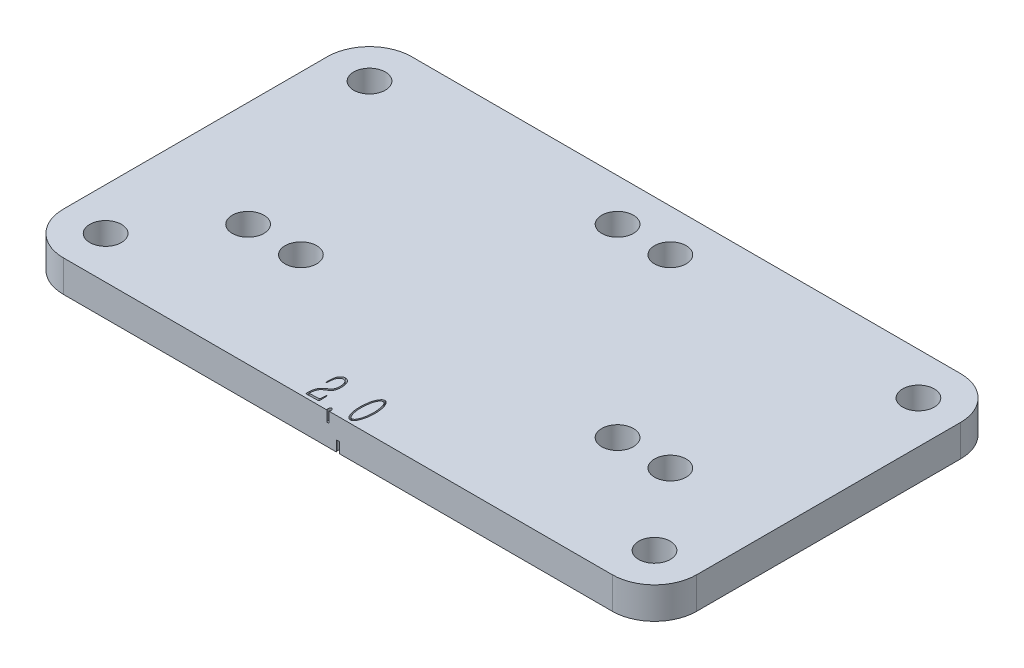
from build123d import *

# Parameters (mm, degrees)
SKETCH_4_W          = 60
SKETCH_4_H          = 33
EXTRUDE_2_DEPTH     = 3
SKETCH_8_R          = 1.5
CUT_EXTRUDE_6_DEPTH = 4
FILLET_2_R          = 4
SKETCH_7_R          = 1.5
CUT_EXTRUDE_7_DEPTH = 4
CUT_EXTRUDE_8_DEPTH = 1
CUT_EXTRUDE_9_DEPTH = 1


with BuildPart() as part:
    # 草图4 → 凸台-拉伸2 (new body)
    with BuildSketch(Plane(origin=(0, 0, 0), x_dir=(1, 0, 0), z_dir=(0, 1, 0))):
        with Locations((-12.012320329, 24.45687885)):
            Rectangle(SKETCH_4_W, SKETCH_4_H)
    extrude(amount=-EXTRUDE_2_DEPTH)

    # 草图8 → 切除-拉伸6 (cut)
    with BuildSketch(Plane(origin=(0, 0, 0), x_dir=(1, 0, 0), z_dir=(0, 1, 0))):
        with Locations((-38.012320329, 36.95687885)):
            Circle(SKETCH_8_R)
        with Locations((13.987679671, 36.95687885)):
            Circle(SKETCH_8_R)
        with Locations((13.987679671, 11.95687885)):
            Circle(SKETCH_8_R)
        with Locations((-38.012320329, 11.95687885)):
            Circle(SKETCH_8_R)
    extrude(amount=-CUT_EXTRUDE_6_DEPTH, mode=Mode.SUBTRACT)

    # 圆角2
    fillet_2_edges = [part.edges().sort_by_distance(p)[0] for p in [
        (-42.012320329, -1.5, -7.95687885),
        (-42.012320329, -1.5, -40.95687885),
        (17.987679671, -1.5, -40.95687885),
        (17.987679671, -1.5, -7.95687885),
    ]]
    fillet(fillet_2_edges, radius=FILLET_2_R)

    # 草图7 → 切除-拉伸7 (cut, through all)
    with BuildSketch(Plane(origin=(0, 0, 0), x_dir=(1, 0, 0), z_dir=(0, 1, 0))):
        with Locations((-14.512320329, 36.95687885)):
            Circle(SKETCH_7_R)
        with Locations((2.987679671, 19.45687885)):
            Circle(SKETCH_7_R)
        with Locations((-32.012320329, 19.45687885)):
            Circle(SKETCH_7_R)
        with Locations((-9.512320329, 36.95687885)):
            Circle(SKETCH_7_R)
        with Locations((7.987679671, 19.45687885)):
            Circle(SKETCH_7_R)
        with Locations((-27.012320329, 19.45687885)):
            Circle(SKETCH_7_R)
    extrude(amount=-CUT_EXTRUDE_7_DEPTH, mode=Mode.SUBTRACT)

    # 草图10 → 切除-拉伸8 (cut)
    with BuildSketch(Plane(origin=(0, 0, 0), x_dir=(1, 0, 0), z_dir=(0, 1, 0))):
        with BuildLine():
            Line((-15.287091264, 10.192016289), (-15.363162008, 10.192016289))
            add(Edge.make_bspline(
                [(-15.363162008, 10.192016289), (-15.364729412, 10.216125544), (-15.367717543, 10.26208793), (-15.370800887, 10.327727204), (-15.372102998, 10.386663248), (-15.373407415, 10.45851319), (-15.371395676, 10.549125051), (-15.365993988, 10.6221094), (-15.363162008, 10.660373416)],
                knots=[0, 0, 0, 0, 7.248e-05, 0.000138177, 0.000197114, 0.000249325, 0.000353759, 0.000468853, 0.000468853, 0.000468853, 0.000468853], degree=3))
            add(Edge.make_bspline(
                [(-15.363162008, 10.660373416), (-15.3612021, 10.688739694), (-15.357411864, 10.743596824), (-15.34740886, 10.82265933), (-15.335832353, 10.895923705), (-15.320781798, 10.96483426), (-15.300446018, 11.03227012), (-15.271495836, 11.100098975), (-15.235389503, 11.170644039), (-15.192730832, 11.241435985), (-15.145924194, 11.308233867), (-15.093385686, 11.362591116), (-15.038399866, 11.404022313), (-14.979896259, 11.428680189), (-14.92372432, 11.44401387), (-14.872500115, 11.456075445), (-14.826468535, 11.464504855), (-14.797385804, 11.465404455), (-14.783681931, 11.465828349)],
                knots=[0, 0, 0, 0, 8.5285e-05, 0.000164931, 0.000238986, 0.000307745, 0.000376394, 0.000449941, 0.000528656, 0.000613967, 0.000697805, 0.000772696, 0.000839975, 0.00090275, 0.000961757, 0.001014582, 0.001060683, 0.001101762, 0.001101762, 0.001101762, 0.001101762], degree=3))
            add(Edge.make_bspline(
                [(-14.783681931, 11.465828349), (-14.766217736, 11.464540667), (-14.731709026, 11.461996248), (-14.68094767, 11.450207253), (-14.631922619, 11.433209283), (-14.569217924, 11.402929262), (-14.495894876, 11.355454365), (-14.433516497, 11.293111961), (-14.39035243, 11.236045645), (-14.359947578, 11.187477797), (-14.333004081, 11.133245042), (-14.299167978, 11.054443003), (-14.263770709, 10.94987198), (-14.238244007, 10.817798054), (-14.221876916, 10.680645161), (-14.214388449, 10.5404336), (-14.212996049, 10.401603983), (-14.221147783, 10.311061559), (-14.225084019, 10.267341241)],
                knots=[0, 0, 0, 0, 5.2466e-05, 0.000103671, 0.000155796, 0.000207836, 0.000312295, 0.000416185, 0.00047048, 0.000526766, 0.000587802, 0.000651945, 0.000784015, 0.000917992, 0.001054714, 0.001198141, 0.001339096, 0.001470713, 0.001470713, 0.001470713, 0.001470713], degree=3))
            add(Edge.make_bspline(
                [(-14.225084019, 10.267341241), (-14.233063394, 10.222368993), (-14.249141197, 10.131753505), (-14.283770883, 10.022653706), (-14.316066991, 9.939709743), (-14.343068232, 9.884128838), (-14.371918792, 9.83492425), (-14.413636529, 9.77673495), (-14.477344962, 9.710683589), (-14.53638122, 9.666388782), (-14.567402366, 9.643113668)],
                knots=[0, 0, 0, 0, 0.000136901, 0.000275845, 0.000342458, 0.000403831, 0.000461005, 0.00051337, 0.000618346, 0.000734587, 0.000734587, 0.000734587, 0.000734587], degree=3))
            Line((-14.567402366, 9.643113668), (-14.814259387, 9.487243223))
            add(Edge.make_bspline(
                [(-14.814259387, 9.487243223), (-14.845716391, 9.465887458), (-14.905364874, 9.425392853), (-14.985012067, 9.359246819), (-15.051862567, 9.289550735), (-15.102391662, 9.212487486), (-15.141636573, 9.133161687), (-15.176484806, 9.05351083), (-15.20279345, 8.965717253), (-15.22150518, 8.887025399), (-15.234265961, 8.82093608), (-15.240658092, 8.77484398), (-15.245850832, 8.734107217), (-15.246509446, 8.708650398), (-15.246818517, 8.696704122)],
                knots=[0, 0, 0, 0, 0.000114009, 0.000216182, 0.000310104, 0.000402565, 0.000491286, 0.000575504, 0.000663016, 0.000765762, 0.000818127, 0.000864851, 0.000905372, 0.000941201, 0.000941201, 0.000941201, 0.000941201], degree=3))
            Line((-15.246818517, 8.696704122), (-15.2572596, 8.485645098))
            Line((-15.2572596, 8.485645098), (-14.356343342, 8.515476762))
            add(Edge.make_bspline(
                [(-14.356343342, 8.515476762), (-14.344783063, 8.516123127), (-14.324478623, 8.5172584), (-14.304964808, 8.538531786), (-14.300621259, 8.564506607), (-14.2929139, 8.596454889), (-14.287184007, 8.6422499), (-14.282763796, 8.677076254), (-14.280272598, 8.696704122)],
                knots=[0, 0, 0, 0, 3.3494e-05, 5.8829e-05, 7.891e-05, 0.000111674, 0.00015766, 0.000217048, 0.000217048, 0.000217048, 0.000217048], degree=3))
            Line((-14.280272598, 8.696704122), (-14.260136225, 9.135229585))
            Line((-14.260136225, 9.135229585), (-14.190031814, 9.135229585))
            Line((-14.190031814, 9.135229585), (-14.164674899, 8.470729266))
            add(Edge.make_bspline(
                [(-14.164674899, 8.470729266), (-14.163827204, 8.457810655), (-14.162344584, 8.435215992), (-14.161622864, 8.405326519), (-14.161602437, 8.384513996), (-14.161917205, 8.367709996), (-14.167329396, 8.353017942), (-14.172358408, 8.335970323), (-14.191976116, 8.326339221), (-14.220175179, 8.323257692), (-14.263031484, 8.318893416), (-14.296667332, 8.319172549), (-14.316070595, 8.31933357)],
                knots=[0, 0, 0, 0, 3.8846e-05, 6.7941e-05, 8.9569e-05, 0.000101525, 0.000117813, 0.000136827, 0.000151537, 0.00017962, 0.000222294, 0.00028047, 0.00028047, 0.00028047, 0.00028047], degree=3))
            Line((-14.316070595, 8.31933357), (-15.31766872, 8.293976655))
            add(Edge.make_bspline(
                [(-15.31766872, 8.293976655), (-15.329844159, 8.293941037), (-15.353842849, 8.293870829), (-15.378435843, 8.317734804), (-15.388759475, 8.346948947), (-15.393926411, 8.381310643), (-15.397387349, 8.426897236), (-15.399049769, 8.505303374), (-15.395495567, 8.616863261), (-15.387489826, 8.708917686), (-15.383298381, 8.757113242)],
                knots=[0, 0, 0, 0, 3.5337e-05, 6.9651e-05, 9.3748e-05, 0.000127835, 0.000173481, 0.000230926, 0.000362984, 0.0005081, 0.0005081, 0.0005081, 0.0005081], degree=3))
            add(Edge.make_bspline(
                [(-15.383298381, 8.757113242), (-15.379578821, 8.785244923), (-15.372413658, 8.839436306), (-15.357845202, 8.917442036), (-15.342312867, 8.989848815), (-15.325456184, 9.056612837), (-15.306847234, 9.117382375), (-15.286535618, 9.172087858), (-15.265479497, 9.221610342), (-15.233852113, 9.27763323), (-15.193656168, 9.338700066), (-15.147935489, 9.404544814), (-15.103915379, 9.460398843), (-15.046378949, 9.521847278), (-14.96848564, 9.588918856), (-14.903050304, 9.638030329), (-14.869447965, 9.663250041)],
                knots=[0, 0, 0, 0, 8.5115e-05, 0.000163961, 0.000237979, 0.000307257, 0.000370478, 0.000428525, 0.00048229, 0.000531692, 0.000621268, 0.000701551, 0.000772134, 0.000834397, 0.000953808, 0.001079855, 0.001079855, 0.001079855, 0.001079855], degree=3))
            Line((-14.869447965, 9.663250041), (-14.662863691, 9.794509364))
            add(Edge.make_bspline(
                [(-14.662863691, 9.794509364), (-14.64632441, 9.805505683), (-14.614585732, 9.826607485), (-14.570747877, 9.860203266), (-14.533374461, 9.895061277), (-14.50116727, 9.932677624), (-14.472011716, 9.976205072), (-14.448067406, 10.030461354), (-14.422753928, 10.094370031), (-14.393239818, 10.19379999), (-14.362808637, 10.325038793), (-14.351143021, 10.487189504), (-14.357374899, 10.6514431), (-14.376426923, 10.760463114), (-14.386175006, 10.816243862)],
                knots=[0, 0, 0, 0, 5.9575e-05, 0.000114323, 0.000165501, 0.00021258, 0.000262637, 0.00032202, 0.000390023, 0.000468816, 0.000632947, 0.00079305, 0.000955026, 0.001124734, 0.001124734, 0.001124734, 0.001124734], degree=3))
            add(Edge.make_bspline(
                [(-14.386175006, 10.816243862), (-14.393520352, 10.844680862), (-14.407846215, 10.900142457), (-14.434960955, 10.980037045), (-14.470059325, 11.052803115), (-14.507626842, 11.1207778), (-14.554691839, 11.180279134), (-14.617383125, 11.223012928), (-14.691444372, 11.251579484), (-14.745618308, 11.256609889), (-14.77398664, 11.259244075)],
                knots=[0, 0, 0, 0, 8.8108e-05, 0.000171839, 0.000252578, 0.000330097, 0.000404769, 0.000477598, 0.000555024, 0.000640139, 0.000640139, 0.000640139, 0.000640139], degree=3))
            add(Edge.make_bspline(
                [(-14.77398664, 11.259244075), (-14.788919036, 11.259396951), (-14.818702747, 11.259701874), (-14.863064269, 11.252974573), (-14.906211961, 11.238869255), (-14.962890377, 11.213304149), (-15.028383427, 11.165683274), (-15.097319789, 11.0938324), (-15.154181325, 11.006100918), (-15.197960353, 10.904436132), (-15.230878923, 10.788612226), (-15.257602358, 10.658805092), (-15.275149735, 10.513368621), (-15.280052172, 10.41157402), (-15.282616514, 10.358327817)],
                knots=[0, 0, 0, 0, 4.4754e-05, 8.9264e-05, 0.000133844, 0.000180568, 0.00027533, 0.000374495, 0.000477921, 0.000587115, 0.000705339, 0.000838586, 0.000984372, 0.001144266, 0.001144266, 0.001144266, 0.001144266], degree=3))
            Line((-15.282616514, 10.358327817), (-15.287091264, 10.192016289))
        make_face()
        with BuildLine():
            add(Edge.make_bspline(
                [(-12.949780375, 8.329774652), (-12.938855743, 8.326825283), (-12.91446102, 8.320239337), (-12.880421886, 8.296553887), (-12.845473417, 8.263815649), (-12.822719842, 8.215893233), (-12.807367641, 8.163149726), (-12.800725478, 8.108261672), (-12.802600981, 8.053473994), (-12.813725568, 8.019363129), (-12.819266845, 8.002372138)],
                knots=[0, 0, 0, 0, 3.3726e-05, 7.531e-05, 0.000122772, 0.000175812, 0.000231747, 0.000287342, 0.000341122, 0.000394497, 0.000394497, 0.000394497, 0.000394497], degree=3))
            add(Edge.make_bspline(
                [(-12.819266845, 8.002372138), (-12.827780246, 7.986945934), (-12.843894652, 7.957746779), (-12.876993214, 7.924310247), (-12.91218069, 7.900874712), (-12.937818278, 7.897871147), (-12.949780375, 7.89646973)],
                knots=[0, 0, 0, 0, 5.2572e-05, 9.9509e-05, 0.00014031, 0.000175999, 0.000175999, 0.000175999, 0.000175999], degree=3))
            add(Edge.make_bspline(
                [(-12.949780375, 7.89646973), (-12.964567702, 7.896577432), (-12.994490541, 7.89679537), (-13.033470251, 7.923224929), (-13.063065588, 7.959205766), (-13.086632766, 8.002901308), (-13.098785648, 8.055435616), (-13.100344245, 8.092805127), (-13.101176071, 8.112749295)],
                knots=[0, 0, 0, 0, 4.3487e-05, 8.7997e-05, 0.000135077, 0.000183115, 0.00023539, 0.000295221, 0.000295221, 0.000295221, 0.000295221], degree=3))
            add(Edge.make_bspline(
                [(-13.101176071, 8.112749295), (-13.100245785, 8.130963299), (-13.098412935, 8.166848511), (-13.086075464, 8.218608892), (-13.063555078, 8.264838862), (-13.030103746, 8.299848331), (-12.991879948, 8.324973913), (-12.963263262, 8.328237159), (-12.949780375, 8.329774652)],
                knots=[0, 0, 0, 0, 5.4626e-05, 0.000107625, 0.000158656, 0.000206671, 0.000251821, 0.000292045, 0.000292045, 0.000292045, 0.000292045], degree=3))
        make_face()
        with BuildLine():
            add(Edge.make_bspline(
                [(-11.735631643, 9.920548145), (-11.733201252, 9.968795133), (-11.728221836, 10.067644172), (-11.714685351, 10.219156397), (-11.694718595, 10.37721879), (-11.671564771, 10.539545766), (-11.639526117, 10.699902115), (-11.598522637, 10.852399672), (-11.546178422, 10.993396837), (-11.493947083, 11.101664602), (-11.449793083, 11.181045185), (-11.417666832, 11.23385106), (-11.387103179, 11.281472962), (-11.356990967, 11.322847583), (-11.327435732, 11.358079036), (-11.300178306, 11.388627692), (-11.272669515, 11.412411291), (-11.238169506, 11.435994909), (-11.196175562, 11.457028995), (-11.147512436, 11.475429993), (-11.100687868, 11.486074385), (-11.07018397, 11.486000407), (-11.0554697, 11.485964723)],
                knots=[0, 0, 0, 0, 0.000144916, 0.000296906, 0.000456198, 0.000622845, 0.000788706, 0.000946476, 0.001096089, 0.001239191, 0.001306631, 0.001368536, 0.001424595, 0.001476356, 0.001521904, 0.001562541, 0.001599024, 0.001630674, 0.001687712, 0.001739387, 0.001786631, 0.001830658, 0.001830658, 0.001830658, 0.001830658], degree=3))
            add(Edge.make_bspline(
                [(-11.0554697, 11.485964723), (-11.041399514, 11.483504389), (-11.01168109, 11.478307781), (-10.967745134, 11.458985782), (-10.921113444, 11.43328969), (-10.871499767, 11.399985274), (-10.82196523, 11.355205685), (-10.776058538, 11.295896412), (-10.733439897, 11.223463066), (-10.680477295, 11.108826125), (-10.6221143, 10.95344355), (-10.576287965, 10.790294082), (-10.546520607, 10.654071866), (-10.527107526, 10.54538855), (-10.51167102, 10.430140869), (-10.49509466, 10.268125041), (-10.480311595, 10.060517467), (-10.477929017, 9.893230875), (-10.476735415, 9.809425196)],
                knots=[0, 0, 0, 0, 4.2712e-05, 9.0215e-05, 0.000142951, 0.000202525, 0.000269047, 0.00034231, 0.000426597, 0.000520674, 0.000720827, 0.000923868, 0.001028463, 0.001139061, 0.001254976, 0.0013772, 0.001627628, 0.001879031, 0.001879031, 0.001879031, 0.001879031], degree=3))
            add(Edge.make_bspline(
                [(-10.476735415, 9.809425196), (-10.481300957, 9.742272624), (-10.4906841, 9.60426008), (-10.513006055, 9.392888316), (-10.549821077, 9.17299631), (-10.596148113, 8.987769009), (-10.640957885, 8.84028845), (-10.678958121, 8.73386786), (-10.721476191, 8.633368847), (-10.766856188, 8.539765364), (-10.814065542, 8.456441142), (-10.862934355, 8.386424664), (-10.914573885, 8.33249789), (-10.967626727, 8.293762257), (-11.019426015, 8.267511685), (-11.068919981, 8.250727435), (-11.116053263, 8.241410931), (-11.146676306, 8.243166251), (-11.161372108, 8.244008618)],
                knots=[0, 0, 0, 0, 0.000201915, 0.000414978, 0.000637389, 0.000870184, 0.000987195, 0.00109972, 0.001209009, 0.001314408, 0.00141163, 0.001496073, 0.00156991, 0.001634502, 0.001692203, 0.001743381, 0.001791077, 0.001835085, 0.001835085, 0.001835085, 0.001835085], degree=3))
            add(Edge.make_bspline(
                [(-11.161372108, 8.244008618), (-11.175414356, 8.245982473), (-11.205000289, 8.250141233), (-11.24959667, 8.267641786), (-11.296037897, 8.294605426), (-11.345617102, 8.330149044), (-11.395540622, 8.378980649), (-11.443614029, 8.442140963), (-11.489715783, 8.519973182), (-11.533527718, 8.610992513), (-11.57467781, 8.712372555), (-11.610709904, 8.821763185), (-11.644092923, 8.936714535), (-11.670841711, 9.056902213), (-11.692853134, 9.178371226), (-11.710123705, 9.297769755), (-11.722241774, 9.41370099), (-11.728781579, 9.525702543), (-11.731068378, 9.632918244), (-11.7334852, 9.734341774), (-11.734997137, 9.829557582), (-11.735425348, 9.890964679), (-11.735631643, 9.920548145)],
                knots=[0, 0, 0, 0, 4.2425e-05, 8.9386e-05, 0.000142484, 0.000203347, 0.000271912, 0.000351124, 0.000440783, 0.000542848, 0.000653918, 0.000768772, 0.00088822, 0.001012877, 0.00113795, 0.001258503, 0.001374715, 0.001487529, 0.001594965, 0.001696417, 0.00179189, 0.001880642, 0.001880642, 0.001880642, 0.001880642], degree=3))
        make_face()
        with BuildLine():
            add(Edge.make_bspline(
                [(-11.604372321, 9.910107062), (-11.604903066, 9.885994246), (-11.606030113, 9.834790201), (-11.607101971, 9.753237119), (-11.605102348, 9.662490533), (-11.60168565, 9.528579982), (-11.589141635, 9.353575696), (-11.557081417, 9.14347498), (-11.511293293, 8.940009127), (-11.460838915, 8.780569844), (-11.413866278, 8.666911627), (-11.377821487, 8.596371241), (-11.339901062, 8.53938423), (-11.300171945, 8.49597676), (-11.259984955, 8.465214578), (-11.222428728, 8.443232578), (-11.186839531, 8.428138109), (-11.162988213, 8.426169556), (-11.151676817, 8.425235978)],
                knots=[0, 0, 0, 0, 7.2357e-05, 0.000153652, 0.000244651, 0.000344631, 0.000555527, 0.000770483, 0.000981616, 0.001180674, 0.001271259, 0.001350316, 0.001417958, 0.001476005, 0.001525979, 0.001569086, 0.001606621, 0.001640479, 0.001640479, 0.001640479, 0.001640479], degree=3))
            add(Edge.make_bspline(
                [(-11.151676817, 8.425235978), (-11.141205004, 8.425370665), (-11.11871169, 8.425659971), (-11.083519848, 8.434123004), (-11.046522874, 8.451937968), (-11.005484922, 8.475348387), (-10.963325674, 8.511377653), (-10.921713744, 8.560615752), (-10.880927778, 8.623720057), (-10.840251409, 8.698338894), (-10.801774514, 8.781356705), (-10.767307314, 8.869311133), (-10.737311613, 8.960104659), (-10.704871006, 9.087130942), (-10.671520499, 9.251879125), (-10.641564121, 9.453063569), (-10.621698056, 9.651460177), (-10.613424885, 9.813313867), (-10.611123605, 9.941430345), (-10.613036103, 10.043380148), (-10.616644464, 10.152783042), (-10.620776071, 10.228317907), (-10.622910569, 10.267341241)],
                knots=[0, 0, 0, 0, 3.1359e-05, 6.7358e-05, 0.000107416, 0.000154229, 0.000208754, 0.00027274, 0.000346998, 0.000433779, 0.000527538, 0.000621298, 0.00071705, 0.000814189, 0.001014424, 0.001221046, 0.001424156, 0.001612346, 0.001707073, 0.001808512, 0.001918206, 0.002035447, 0.002035447, 0.002035447, 0.002035447], degree=3))
            add(Edge.make_bspline(
                [(-10.622910569, 10.267341241), (-10.626507391, 10.303898163), (-10.633488769, 10.374854623), (-10.645762556, 10.477403359), (-10.660993, 10.572578195), (-10.682453812, 10.689831602), (-10.71709719, 10.83052392), (-10.764815996, 10.964467256), (-10.80597291, 11.065595745), (-10.841348451, 11.129670189), (-10.877328168, 11.184046987), (-10.917310685, 11.225543336), (-10.956229108, 11.257879918), (-10.99285861, 11.282048376), (-11.027070692, 11.299112465), (-11.050108892, 11.302966994), (-11.060690241, 11.304737363)],
                knots=[0, 0, 0, 0, 0.000110201, 0.000213898, 0.000309781, 0.000399301, 0.000571499, 0.000743679, 0.000825546, 0.000898637, 0.000962975, 0.001020478, 0.001070801, 0.001114447, 0.00115216, 0.001184194, 0.001184194, 0.001184194, 0.001184194], degree=3))
            add(Edge.make_bspline(
                [(-11.060690241, 11.304737363), (-11.072192711, 11.303900341), (-11.096363494, 11.302141461), (-11.133262385, 11.290831294), (-11.172426004, 11.273145928), (-11.215452645, 11.248614257), (-11.260274093, 11.209241229), (-11.305531786, 11.151607254), (-11.35236172, 11.075159608), (-11.401239633, 10.981052633), (-11.447941194, 10.870175973), (-11.487620227, 10.743176728), (-11.521908142, 10.602203385), (-11.547734641, 10.451230536), (-11.568597278, 10.300131226), (-11.584864295, 10.158105995), (-11.59732638, 10.029581347), (-11.602113534, 9.94840811), (-11.604372321, 9.910107062)],
                knots=[0, 0, 0, 0, 3.4508e-05, 7.2515e-05, 0.00011492, 0.000163396, 0.000220507, 0.000292606, 0.000382411, 0.000489153, 0.000610488, 0.000742805, 0.000887874, 0.001045434, 0.001202059, 0.001345447, 0.001474277, 0.001589371, 0.001589371, 0.001589371, 0.001589371], degree=3))
        make_face(mode=Mode.SUBTRACT)
    extrude(amount=-CUT_EXTRUDE_8_DEPTH, mode=Mode.SUBTRACT)

    # 草图12 → 切除-拉伸9 (cut)
    with BuildSketch(Plane.XZ.offset(3)):
        with BuildLine():
            add(Edge.make_bspline(
                [(-13.190671064, -9.93248081), (-13.193079607, -9.980730661), (-13.19801426, -10.079585565), (-13.211902, -10.231021843), (-13.230392314, -10.388999739), (-13.254487132, -10.550580843), (-13.284497126, -10.710738939), (-13.328557178, -10.862563492), (-13.380720563, -11.00499875), (-13.434524545, -11.114759739), (-13.479374893, -11.195772714), (-13.51231387, -11.250135049), (-13.545360579, -11.298156116), (-13.5759532, -11.341727107), (-13.60709368, -11.378435553), (-13.636578419, -11.410286673), (-13.666322552, -11.435526177), (-13.703821425, -11.461247625), (-13.750354811, -11.484075269), (-13.805270339, -11.504149269), (-13.85967676, -11.515387151), (-13.895647035, -11.515161572), (-13.913343128, -11.515050595)],
                knots=[0, 0, 0, 0, 0.000144916, 0.000296906, 0.000456109, 0.000622019, 0.000787002, 0.000944456, 0.001095727, 0.001241492, 0.001310598, 0.001373528, 0.001432067, 0.001485473, 0.001533122, 0.001576378, 0.00161553, 0.001649869, 0.001712573, 0.001770366, 0.001825069, 0.001878041, 0.001878041, 0.001878041, 0.001878041], degree=3))
            add(Edge.make_bspline(
                [(-13.913343128, -11.515050595), (-13.933887764, -11.511716224), (-13.975820647, -11.504910563), (-14.036705992, -11.482280538), (-14.097293046, -11.452276356), (-14.156257951, -11.412569313), (-14.213428225, -11.362185326), (-14.264075959, -11.297814155), (-14.311902671, -11.222347341), (-14.366691808, -11.104796768), (-14.424693069, -10.948813931), (-14.471294329, -10.787183153), (-14.499982037, -10.653083289), (-14.518199146, -10.544766235), (-14.535081693, -10.429230309), (-14.550887505, -10.266588693), (-14.566053721, -10.06326641), (-14.567962497, -9.900691676), (-14.568893949, -9.821357861)],
                knots=[0, 0, 0, 0, 6.2308e-05, 0.000127175, 0.000193881, 0.000264829, 0.000339832, 0.000421482, 0.000509627, 0.00060736, 0.000809869, 0.001008403, 0.001111381, 0.001221117, 0.001337873, 0.00146158, 0.001711264, 0.001949229, 0.001949229, 0.001949229, 0.001949229], degree=3))
            add(Edge.make_bspline(
                [(-14.568893949, -9.821357861), (-14.564307402, -9.754456871), (-14.555000266, -9.61869972), (-14.533474566, -9.411511623), (-14.496951163, -9.197481013), (-14.452278131, -9.016276891), (-14.407618792, -8.871017919), (-14.368412634, -8.764984958), (-14.326403684, -8.662848955), (-14.279985208, -8.566632124), (-14.230213283, -8.479023001), (-14.17410058, -8.405208525), (-14.113980344, -8.345492182), (-14.049305989, -8.301175317), (-13.983381587, -8.27058234), (-13.919930996, -8.247971955), (-13.857799074, -8.236696186), (-13.817415839, -8.238102883), (-13.79774543, -8.238788077)],
                knots=[0, 0, 0, 0, 0.000201172, 0.000408223, 0.000624627, 0.000851995, 0.000967581, 0.001080361, 0.001191025, 0.001298763, 0.001400707, 0.001492742, 0.001576071, 0.001653852, 0.001726573, 0.001793553, 0.001855593, 0.001914511, 0.001914511, 0.001914511, 0.001914511], degree=3))
            add(Edge.make_bspline(
                [(-13.79774543, -8.238788077), (-13.781929783, -8.240615407), (-13.748383533, -8.244491319), (-13.698595898, -8.264688958), (-13.646558993, -8.29347845), (-13.592768054, -8.332506622), (-13.538171165, -8.383416396), (-13.488040929, -8.450458581), (-13.439606745, -8.530757103), (-13.394502174, -8.623908208), (-13.352249985, -8.726729182), (-13.315555193, -8.837091533), (-13.282381664, -8.9529182), (-13.255326411, -9.073287553), (-13.233895877, -9.19462918), (-13.214823447, -9.313542877), (-13.204463355, -9.429178989), (-13.197323448, -9.540605614), (-13.19563292, -9.647105696), (-13.191526185, -9.747746061), (-13.191594563, -9.842243269), (-13.190971265, -9.903147344), (-13.190671064, -9.93248081)],
                knots=[0, 0, 0, 0, 4.7573e-05, 0.000100906, 0.000159654, 0.000225891, 0.00029975, 0.000382691, 0.000476061, 0.000580791, 0.000692834, 0.00080934, 0.000929505, 0.001054161, 0.001179234, 0.001299158, 0.001415296, 0.001527366, 0.001634056, 0.001734782, 0.0018295, 0.001917507, 0.001917507, 0.001917507, 0.001917507], degree=3))
        make_face()
        with BuildLine():
            add(Edge.make_bspline(
                [(-13.461393416, -9.919802353), (-13.460861356, -9.896683989), (-13.459717257, -9.846972064), (-13.458663819, -9.767655228), (-13.460680395, -9.678650499), (-13.464046542, -9.546966795), (-13.476879599, -9.375031503), (-13.502380411, -9.202418884), (-13.531700724, -9.067080684), (-13.554527886, -8.969065034), (-13.583810541, -8.876735635), (-13.613043493, -8.789976755), (-13.645012549, -8.713442384), (-13.673920227, -8.648524335), (-13.705581992, -8.600031673), (-13.735818469, -8.565381735), (-13.763429827, -8.542391247), (-13.784884018, -8.525801336), (-13.801196383, -8.514992802), (-13.811109473, -8.512105609), (-13.814898637, -8.511002012)],
                knots=[0, 0, 0, 0, 6.9375e-05, 0.000149178, 0.00023794, 0.000336429, 0.00054435, 0.00075477, 0.000859208, 0.000959779, 0.001056502, 0.001149667, 0.001234287, 0.001305341, 0.001362432, 0.001407334, 0.001442765, 0.001469912, 0.00148897, 0.001500762, 0.001500762, 0.001500762, 0.001500762], degree=3))
            add(Edge.make_bspline(
                [(-13.814898637, -8.511002012), (-13.822656412, -8.511151683), (-13.839504555, -8.511476735), (-13.866109842, -8.52012764), (-13.895986723, -8.533602063), (-13.929443476, -8.554082993), (-13.965620282, -8.584855385), (-14.001503803, -8.629778533), (-14.038427516, -8.68788679), (-14.076482606, -8.757214736), (-14.111688889, -8.835586048), (-14.145091052, -8.918682435), (-14.173240621, -9.005955306), (-14.20478922, -9.128384061), (-14.23704754, -9.288161762), (-14.265155647, -9.483219837), (-14.284017734, -9.675103949), (-14.293434016, -9.830454036), (-14.293785358, -9.953363919), (-14.293513846, -10.051341561), (-14.289390044, -10.157505911), (-14.285351225, -10.230803711), (-14.283255764, -10.268832824)],
                knots=[0, 0, 0, 0, 2.3168e-05, 5.0315e-05, 8.3028e-05, 0.000121528, 0.000167556, 0.000224754, 0.000293225, 0.000373995, 0.000461764, 0.000550813, 0.000642558, 0.000736622, 0.000929982, 0.001131222, 0.001327579, 0.001508321, 0.001597819, 0.001696266, 0.001802234, 0.001916496, 0.001916496, 0.001916496, 0.001916496], degree=3))
            add(Edge.make_bspline(
                [(-14.283255764, -10.268832824), (-14.280002781, -10.30366184), (-14.273672716, -10.37143654), (-14.260707966, -10.469600453), (-14.246964251, -10.561485443), (-14.224957453, -10.674533032), (-14.192013705, -10.80935483), (-14.147777316, -10.937200786), (-14.109101127, -11.031517834), (-14.077197548, -11.090430424), (-14.045431613, -11.139294082), (-14.011031882, -11.176250336), (-13.978531776, -11.204254642), (-13.94818234, -11.2228887), (-13.923145668, -11.238527605), (-13.906035726, -11.241510313), (-13.898427296, -11.24283666)],
                knots=[0, 0, 0, 0, 0.000104932, 0.000204189, 0.000297009, 0.000383598, 0.000549647, 0.000712855, 0.000789042, 0.000855111, 0.00091365, 0.000963266, 0.001006141, 0.001041721, 0.001070412, 0.001093387, 0.001093387, 0.001093387, 0.001093387], degree=3))
            add(Edge.make_bspline(
                [(-13.898427296, -11.24283666), (-13.893905436, -11.242273426), (-13.882711453, -11.240879127), (-13.864610386, -11.232553068), (-13.841867433, -11.220197972), (-13.812668335, -11.203067353), (-13.778916574, -11.171462551), (-13.742667694, -11.121444785), (-13.703085327, -11.051473538), (-13.657668507, -10.964230788), (-13.613265095, -10.858428497), (-13.574825472, -10.73559234), (-13.543415246, -10.597025922), (-13.51802419, -10.447966508), (-13.497336791, -10.298619122), (-13.480947431, -10.159099705), (-13.46853043, -10.034551427), (-13.463667346, -9.956362654), (-13.461393416, -9.919802353)],
                knots=[0, 0, 0, 0, 1.3609e-05, 3.369e-05, 5.9047e-05, 9.1539e-05, 0.000134833, 0.000196585, 0.000276144, 0.000375874, 0.00049153, 0.00061984, 0.00076149, 0.000917451, 0.001073338, 0.001213763, 0.00133888, 0.001448765, 0.001448765, 0.001448765, 0.001448765], degree=3))
        make_face(mode=Mode.SUBTRACT)
        with BuildLine():
            add(Edge.make_bspline(
                [(-11.972047582, -8.41703227), (-11.995265306, -8.412156554), (-12.041207531, -8.402508697), (-12.102906372, -8.369413007), (-12.150989441, -8.323068031), (-12.183248223, -8.267831808), (-12.198837888, -8.209547779), (-12.207835638, -8.151047849), (-12.202460925, -8.089490945), (-12.187854632, -8.0500807), (-12.18012344, -8.029220636)],
                knots=[0, 0, 0, 0, 7.0909e-05, 0.000140312, 0.000206767, 0.000268932, 0.00032958, 0.000386749, 0.000445897, 0.000512411, 0.000512411, 0.000512411, 0.000512411], degree=3))
            add(Edge.make_bspline(
                [(-12.18012344, -8.029220636), (-12.170318964, -8.013792806), (-12.148952049, -7.980170906), (-12.109680677, -7.946202936), (-12.072296267, -7.921738808), (-12.040529136, -7.90724659), (-12.005922824, -7.900007057), (-11.982516163, -7.898653132), (-11.970555999, -7.897961313)],
                knots=[0, 0, 0, 0, 5.4621e-05, 0.000119036, 0.000153585, 0.000188645, 0.000223024, 0.000258947, 0.000258947, 0.000258947, 0.000258947], degree=3))
            add(Edge.make_bspline(
                [(-11.970555999, -7.897961313), (-11.96007322, -7.897448045), (-11.939357254, -7.89643373), (-11.909528957, -7.903805661), (-11.881379735, -7.915633338), (-11.84988495, -7.941241288), (-11.815254434, -7.977415639), (-11.787743417, -8.030872918), (-11.771566821, -8.091402001), (-11.770018058, -8.13451118), (-11.769192265, -8.157496792)],
                knots=[0, 0, 0, 0, 3.1323e-05, 6.1901e-05, 9.1281e-05, 0.000122158, 0.000182861, 0.000240243, 0.000300486, 0.000369297, 0.000369297, 0.000369297, 0.000369297], degree=3))
            add(Edge.make_bspline(
                [(-11.769192265, -8.157496792), (-11.770234711, -8.178220735), (-11.7723244, -8.219763986), (-11.787972559, -8.280046068), (-11.815169682, -8.336026363), (-11.857204521, -8.38106611), (-11.911158455, -8.412550792), (-11.9517605, -8.415539128), (-11.972047582, -8.41703227)],
                knots=[0, 0, 0, 0, 6.212e-05, 0.000124527, 0.000185563, 0.000246773, 0.000307187, 0.000367517, 0.000367517, 0.000367517, 0.000367517], degree=3))
        make_face()
        with BuildLine():
            Line((-9.63771986, -10.174863082), (-9.47066254, -10.150997751))
            add(Edge.make_bspline(
                [(-9.47066254, -10.150997751), (-9.468967853, -10.181577419), (-9.46581273, -10.23850984), (-9.460760112, -10.317761846), (-9.458659456, -10.384915254), (-9.457503706, -10.460006096), (-9.459435922, -10.550864782), (-9.464837052, -10.623103758), (-9.467679374, -10.661119208)],
                knots=[0, 0, 0, 0, 9.1881e-05, 0.000171061, 0.00023822, 0.000293413, 0.000396357, 0.000510707, 0.000510707, 0.000510707, 0.000510707], degree=3))
            add(Edge.make_bspline(
                [(-9.467679374, -10.661119208), (-9.469659511, -10.69022659), (-9.47347524, -10.746316559), (-9.483153697, -10.827220137), (-9.495977289, -10.901549854), (-9.510535561, -10.971690947), (-9.532174115, -11.039892269), (-9.561620595, -11.109774775), (-9.600278686, -11.182642927), (-9.644509769, -11.257231655), (-9.694712347, -11.327053582), (-9.751009895, -11.384764441), (-9.81116697, -11.428489156), (-9.874291924, -11.45639158), (-9.935384977, -11.473159912), (-9.990850302, -11.486030457), (-10.040450381, -11.49424762), (-10.071496437, -11.495211547), (-10.085940614, -11.495660014)],
                knots=[0, 0, 0, 0, 8.7515e-05, 0.000168642, 0.000244291, 0.000313778, 0.000383361, 0.000458571, 0.000540964, 0.000630623, 0.00071863, 0.000798262, 0.000871521, 0.000940279, 0.001004, 0.001061353, 0.001111137, 0.001154451, 0.001154451, 0.001154451, 0.001154451], degree=3))
            add(Edge.make_bspline(
                [(-10.085940614, -11.495660014), (-10.108910704, -11.494076419), (-10.153766147, -11.490984013), (-10.21855363, -11.475318593), (-10.280789504, -11.457292436), (-10.338004497, -11.429330274), (-10.391647407, -11.398568169), (-10.440153959, -11.363303946), (-10.484045135, -11.325024111), (-10.522876838, -11.282735517), (-10.558924888, -11.236847157), (-10.589253206, -11.184944982), (-10.619264645, -11.129463318), (-10.652883146, -11.048614926), (-10.6874939, -10.944422149), (-10.71493761, -10.815515822), (-10.728439312, -10.681002324), (-10.737689921, -10.541228695), (-10.738641424, -10.401096645), (-10.73047584, -10.30956781), (-10.726575602, -10.265849658)],
                knots=[0, 0, 0, 0, 6.894e-05, 0.000134625, 0.000199492, 0.000262884, 0.000325049, 0.000384871, 0.000442471, 0.000499464, 0.000556895, 0.000617138, 0.000679522, 0.000746015, 0.000879501, 0.001008368, 0.001140472, 0.001284688, 0.001428625, 0.001560242, 0.001560242, 0.001560242, 0.001560242], degree=3))
            add(Edge.make_bspline(
                [(-10.726575602, -10.265849658), (-10.718792873, -10.222385098), (-10.703063123, -10.13453845), (-10.669334966, -10.027922765), (-10.636002934, -9.946052292), (-10.608566084, -9.889380234), (-10.578944985, -9.83809363), (-10.544941558, -9.79229318), (-10.507120892, -9.74877478), (-10.462584754, -9.707603451), (-10.413301202, -9.665151061), (-10.377009749, -9.638869326), (-10.35815455, -9.625214669)],
                knots=[0, 0, 0, 0, 0.000132367, 0.000267528, 0.000334421, 0.000397462, 0.000456299, 0.000511789, 0.000568336, 0.000629003, 0.000693556, 0.000763362, 0.000763362, 0.000763362, 0.000763362], degree=3))
            Line((-10.35815455, -9.625214669), (-10.105331196, -9.465615266))
            add(Edge.make_bspline(
                [(-10.105331196, -9.465615266), (-10.081681282, -9.449595008), (-10.034356369, -9.417537499), (-9.968501332, -9.362520932), (-9.910173999, -9.300570039), (-9.862713105, -9.230703146), (-9.82540499, -9.155826212), (-9.793393594, -9.07646423), (-9.766433085, -8.99068724), (-9.745355178, -8.899902698), (-9.729095975, -8.812073156), (-9.725743575, -8.755177946), (-9.724231686, -8.729518952)],
                knots=[0, 0, 0, 0, 8.5659e-05, 0.000171409, 0.000256899, 0.000340057, 0.000423775, 0.000507424, 0.000596582, 0.000693179, 0.000786974, 0.000864022, 0.000864022, 0.000864022, 0.000864022], degree=3))
            Line((-9.724231686, -8.729518952), (-9.715282187, -8.571411132))
            Line((-9.715282187, -8.571411132), (-10.502092329, -8.599751213))
            add(Edge.make_bspline(
                [(-10.502092329, -8.599751213), (-10.504737209, -8.600187479), (-10.509717707, -8.601009), (-10.515403847, -8.608119506), (-10.516684282, -8.62296461), (-10.519856616, -8.648913385), (-10.525217533, -8.690739524), (-10.528993187, -8.723806792), (-10.531178202, -8.742943201)],
                knots=[0, 0, 0, 0, 7.786e-06, 1.4662e-05, 2.534e-05, 5.1613e-05, 9.3702e-05, 0.000151519, 0.000151519, 0.000151519, 0.000151519], degree=3))
            Line((-10.531178202, -8.742943201), (-10.552060367, -9.208317162))
            Line((-10.552060367, -9.208317162), (-10.759390433, -9.208317162))
            Line((-10.759390433, -9.208317162), (-10.785493139, -8.510256221))
            add(Edge.make_bspline(
                [(-10.785493139, -8.510256221), (-10.786404485, -8.496841354), (-10.788006918, -8.473253784), (-10.788093551, -8.442603976), (-10.789441661, -8.421803762), (-10.788908265, -8.403762883), (-10.778434099, -8.382244823), (-10.769311872, -8.360245835), (-10.755450213, -8.342280575), (-10.740146402, -8.334938481), (-10.72096302, -8.327092524), (-10.695818599, -8.322681546), (-10.665780944, -8.318113125), (-10.630210384, -8.31417755), (-10.589104681, -8.313286168), (-10.560014117, -8.312851647), (-10.544602451, -8.312621445)],
                knots=[0, 0, 0, 0, 4.0335e-05, 7.0921e-05, 9.1817e-05, 0.000103029, 0.000124502, 0.000162192, 0.000174892, 0.000191266, 0.000212041, 0.0002372, 0.000267365, 0.000303357, 0.000344403, 0.000390648, 0.000390648, 0.000390648, 0.000390648], degree=3))
            Line((-10.544602451, -8.312621445), (-9.566869657, -8.288010323))
            add(Edge.make_bspline(
                [(-9.566869657, -8.288010323), (-9.555907144, -8.28774612), (-9.535157194, -8.287246036), (-9.505593973, -8.294476995), (-9.481754971, -8.310163385), (-9.462328076, -8.33263408), (-9.449715287, -8.36426161), (-9.438712786, -8.404654438), (-9.435148387, -8.456021468), (-9.431919797, -8.539041389), (-9.436137101, -8.653434993), (-9.444156749, -8.746960517), (-9.448288792, -8.795148614)],
                knots=[0, 0, 0, 0, 3.2823e-05, 6.2128e-05, 8.9642e-05, 0.000117145, 0.000149858, 0.000190741, 0.000242465, 0.000303661, 0.000440191, 0.000585307, 0.000585307, 0.000585307, 0.000585307], degree=3))
            add(Edge.make_bspline(
                [(-9.448288792, -8.795148614), (-9.452025941, -8.823525405), (-9.459259098, -8.87844797), (-9.473662985, -8.957478121), (-9.489209681, -9.030630923), (-9.506187061, -9.098188181), (-9.525521787, -9.159887453), (-9.546381968, -9.215911099), (-9.56831641, -9.266398281), (-9.60116637, -9.323345413), (-9.641232288, -9.386640348), (-9.689253003, -9.453722671), (-9.734053622, -9.512130739), (-9.794754748, -9.574436777), (-9.872655685, -9.645104658), (-9.939803487, -9.694646758), (-9.974071873, -9.719930203)],
                knots=[0, 0, 0, 0, 8.5854e-05, 0.000166167, 0.000240914, 0.000310193, 0.000375059, 0.000434765, 0.000489513, 0.00053993, 0.000631792, 0.000714154, 0.000787417, 0.000852301, 0.00097481, 0.001102495, 0.001102495, 0.001102495, 0.001102495], degree=3))
            Line((-9.974071873, -9.719930203), (-10.176181398, -9.848206359))
            add(Edge.make_bspline(
                [(-10.176181398, -9.848206359), (-10.191526545, -9.857890156), (-10.220967747, -9.876469489), (-10.260351589, -9.90725208), (-10.294703219, -9.93777687), (-10.323627972, -9.971137048), (-10.348668781, -10.010816257), (-10.371365856, -10.059816476), (-10.393338997, -10.119541804), (-10.421837775, -10.212377446), (-10.44949338, -10.335927891), (-10.462036602, -10.488642968), (-10.455257318, -10.644222643), (-10.436925414, -10.747537007), (-10.427513169, -10.800582238)],
                knots=[0, 0, 0, 0, 5.4402e-05, 0.000104376, 0.000149777, 0.000192084, 0.000236356, 0.000290064, 0.000353784, 0.000427149, 0.000581332, 0.000732514, 0.000885549, 0.001047034, 0.001047034, 0.001047034, 0.001047034], degree=3))
            add(Edge.make_bspline(
                [(-10.427513169, -10.800582238), (-10.421012136, -10.827067661), (-10.408416228, -10.878383812), (-10.382513282, -10.950972539), (-10.353807325, -11.017769986), (-10.320387782, -11.077901487), (-10.27845738, -11.129036332), (-10.22497179, -11.166618063), (-10.161442893, -11.191214773), (-10.11525569, -11.195732431), (-10.091161155, -11.198089163)],
                knots=[0, 0, 0, 0, 8.1765e-05, 0.000158423, 0.000230891, 0.000299714, 0.000364267, 0.000427383, 0.000493725, 0.000566078, 0.000566078, 0.000566078, 0.000566078], degree=3))
            add(Edge.make_bspline(
                [(-10.091161155, -11.198089163), (-10.072311816, -11.19776415), (-10.033225773, -11.197090203), (-9.974585159, -11.171794785), (-9.918407739, -11.127636531), (-9.862429753, -11.067006138), (-9.812099636, -10.988893889), (-9.772131892, -10.892933842), (-9.739807059, -10.780734834), (-9.714688618, -10.651927274), (-9.69584697, -10.509456698), (-9.69094886, -10.410095448), (-9.688433689, -10.359073608)],
                knots=[0, 0, 0, 0, 5.6113e-05, 0.000116356, 0.000187206, 0.000269535, 0.00036283, 0.000464381, 0.000580248, 0.000712615, 0.000857755, 0.00101095, 0.00101095, 0.00101095, 0.00101095], degree=3))
            Line((-9.688433689, -10.359073608), (-9.684704731, -10.197982622))
            Line((-9.684704731, -10.197982622), (-9.63771986, -10.174863082))
        make_face()
    extrude(amount=-CUT_EXTRUDE_9_DEPTH, mode=Mode.SUBTRACT)


solid = part.part
